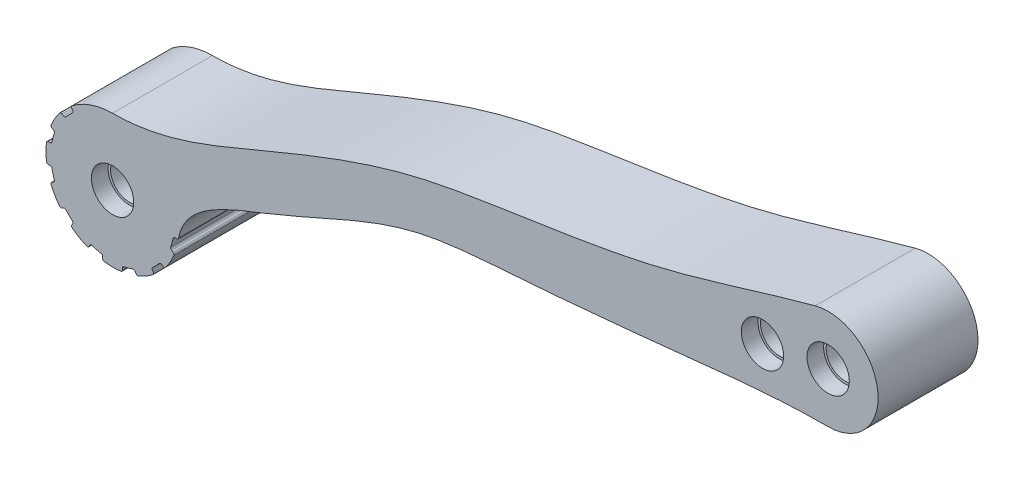
from build123d import *

# Parameters (mm, degrees)
CROQUIS2_R              = 6.35
SALIENTE_EXTRUIR1_DEPTH = 30
CROQUIS5_R              = 7.443338
CROQUIS5_R_2            = 2.5
CROQUIS5_R_3            = 7.334997
SALIENTE_EXTRUIR4_DEPTH = 30
CROQUIS6_R              = 6.35
CORTAR_EXTRUIR2_DEPTH   = 5
CROQUIS7_R              = 5.6
CORTAR_EXTRUIR3_DEPTH   = 30
CROQUIS8_R              = 6.35
CROQUIS8_R_2            = 5.6
CORTAR_EXTRUIR4_DEPTH   = 5
CROQUIS9_R              = 5.6
CORTAR_EXTRUIR6_DEPTH   = 30
CROQUIS10_R             = 6.35
CORTAR_EXTRUIR7_DEPTH   = 5
CROQUIS11_R             = 6.35
CORTAR_EXTRUIR8_DEPTH   = 5
CROQUIS14_R             = 6.35
CROQUIS14_R_2           = 5.6
SALIENTE_EXTRUIR5_DEPTH = 30
CROQUIS15_R             = 6.35
CORTAR_EXTRUIR9_DEPTH   = 5
CROQUIS16_R             = 6.35
CORTAR_EXTRUIR10_DEPTH  = 5
CORTAR_EXTRUIR11_DEPTH  = 30
CORTAR_EXTRUIR12_DEPTH  = 30


with BuildPart() as part:
    # Croquis2 → Saliente-Extruir1 (new body)
    with BuildSketch(Plane.XY):
        with BuildLine():
            ThreePointArc((180.032921, 90.655997), (194.905493, 107.607048), (176.163968, 120.14845))
            add(Edge.make_bspline(
                [(176.163968, 120.14845), (160.644333, 116.005277), (131.164286, 105.63785), (89.902158, 99.637145), (47.577901, 93.169368), (9.263632, 77.144895), (-20.334547, 64.717915), (-34.842858, 64.717915)],
                knots=[0, 0, 0, 0, 0.21855, 0.429652, 0.570361, 0.803751, 1, 1, 1, 1], degree=3))
            ThreePointArc((-34.842858, 64.717915), (-49.983575, 31.650448), (-15.057777, 41.793784))
            add(Edge.make_bspline(
                [(-15.057777, 41.793784), (-13.422876, 52.855749), (19.931915, 63.726677), (50.067366, 80.671919), (92.860268, 83.147923), (133.388153, 87.091721), (164.275892, 90.655997), (180.032921, 90.655997)],
                knots=[0, 0, 0, 0, 0.164668, 0.401388, 0.54424, 0.773428, 1, 1, 1, 1], degree=3))
        make_face()
        with Locations((160.312855, 102.321484)):
            Circle(CROQUIS2_R, mode=Mode.SUBTRACT)
        with Locations((180.032921, 105.655997)):
            Circle(CROQUIS2_R, mode=Mode.SUBTRACT)
        with Locations((-34.842858, 44.717915)):
            Circle(CROQUIS2_R, mode=Mode.SUBTRACT)
    extrude(amount=SALIENTE_EXTRUIR1_DEPTH)

    # Croquis5 → Saliente-Extruir4 (add)
    with BuildSketch(Plane(origin=(0, 0, 0), x_dir=(-1, 0, 0), z_dir=(0, 0, -1))):
        with Locations((-180.032921, 105.655997)):
            Circle(CROQUIS5_R)
        with Locations((-180.032921, 105.655997)):
            Circle(CROQUIS5_R_2, mode=Mode.SUBTRACT)
        with Locations((-160.312855, 102.321484)):
            Circle(CROQUIS5_R_3)
        with Locations((-160.312855, 102.321484)):
            Circle(CROQUIS5_R_2, mode=Mode.SUBTRACT)
    extrude(amount=-SALIENTE_EXTRUIR4_DEPTH)

    # Croquis6 → Cortar-Extruir2 (cut)
    with BuildSketch(Plane(origin=(0, 0, 0), x_dir=(-1, 0, 0), z_dir=(0, 0, -1))):
        with Locations((-160.312855, 102.321484)):
            Circle(CROQUIS6_R)
    extrude(amount=-CORTAR_EXTRUIR2_DEPTH, mode=Mode.SUBTRACT)

    # Croquis7 → Cortar-Extruir3 (cut)
    with BuildSketch(Plane(origin=(0, 0, 5), x_dir=(-1, 0, 0), z_dir=(0, 0, -1))):
        with Locations((-160.312855, 102.321484)):
            Circle(CROQUIS7_R)
    extrude(amount=-CORTAR_EXTRUIR3_DEPTH, mode=Mode.SUBTRACT)

    # Croquis8 → Cortar-Extruir4 (cut)
    with BuildSketch(Plane.XY.offset(30)):
        with Locations(Location((160.312855, 102.321484, 0), (0, 0, 180))):
            Circle(CROQUIS8_R)
        with Locations(Location((160.312855, 102.321484, 0), (0, 0, 180))):
            Circle(CROQUIS8_R_2, mode=Mode.SUBTRACT)
    extrude(amount=-CORTAR_EXTRUIR4_DEPTH, mode=Mode.SUBTRACT)

    # Croquis9 → Cortar-Extruir6 (cut)
    with BuildSketch(Plane(origin=(0, 0, 0), x_dir=(-1, 0, 0), z_dir=(0, 0, -1))):
        with Locations((-180.032921, 105.655997)):
            Circle(CROQUIS9_R)
    extrude(amount=-CORTAR_EXTRUIR6_DEPTH, mode=Mode.SUBTRACT)

    # Croquis10 → Cortar-Extruir7 (cut)
    with BuildSketch(Plane(origin=(0, 0, 0), x_dir=(-1, 0, 0), z_dir=(0, 0, -1))):
        with Locations((-180.032921, 105.655997)):
            Circle(CROQUIS10_R)
    extrude(amount=-CORTAR_EXTRUIR7_DEPTH, mode=Mode.SUBTRACT)

    # Croquis11 → Cortar-Extruir8 (cut)
    with BuildSketch(Plane.XY.offset(30)):
        with Locations(Location((180.032921, 105.655997, 0), (0, 0, 180))):
            Circle(CROQUIS11_R)
    extrude(amount=-CORTAR_EXTRUIR8_DEPTH, mode=Mode.SUBTRACT)

    # Croquis14 → Saliente-Extruir5 (add)
    with BuildSketch(Plane(origin=(0, 0, 0), x_dir=(-1, 0, 0), z_dir=(0, 0, -1))):
        with Locations((34.842858, 44.717915)):
            Circle(CROQUIS14_R)
        with Locations((34.842858, 44.717915)):
            Circle(CROQUIS14_R_2, mode=Mode.SUBTRACT)
    extrude(amount=-SALIENTE_EXTRUIR5_DEPTH)

    # Croquis15 → Cortar-Extruir9 (cut)
    with BuildSketch(Plane(origin=(0, 0, 0), x_dir=(-1, 0, 0), z_dir=(0, 0, -1))):
        with Locations((34.842858, 44.717915)):
            Circle(CROQUIS15_R)
    extrude(amount=-CORTAR_EXTRUIR9_DEPTH, mode=Mode.SUBTRACT)

    # Croquis16 → Cortar-Extruir10 (cut)
    with BuildSketch(Plane.XY.offset(30)):
        with Locations(Location((-34.842858, 44.717915, 0), (0, 0, 180))):
            Circle(CROQUIS16_R)
    extrude(amount=-CORTAR_EXTRUIR10_DEPTH, mode=Mode.SUBTRACT)

    # Croquis17 → Cortar-Extruir11 (cut)
    with BuildSketch(Plane(origin=(0, 0, 0), x_dir=(-1, 0, 0), z_dir=(0, 0, -1))):
        with BuildLine():
            Line((37.842858, 25.961909), (37.840378, 25.443819))
            ThreePointArc((37.840378, 25.443819), (37.696791, 25.063997), (37.337849, 24.87415))
            ThreePointArc((37.337849, 24.87415), (40.019239, 25.399398), (42.604016, 26.285215))
            ThreePointArc((42.604016, 26.285215), (42.198239, 26.270156), (41.883978, 26.527298))
            Line((41.883978, 26.527298), (41.622785, 26.974738))
            ThreePointArc((41.622785, 26.974738), (41.313642, 27.236121), (40.908833, 27.240674))
            ThreePointArc((40.908833, 27.240674), (39.631011, 26.848287), (38.328191, 26.549193))
            ThreePointArc((38.328191, 26.549193), (37.979893, 26.342846), (37.842858, 25.961909))
        make_face()
        with BuildLine():
            ThreePointArc((27.081701, 26.285215), (29.666477, 25.399398), (32.347868, 24.87415))
            ThreePointArc((32.347868, 24.87415), (31.988925, 25.063997), (31.845339, 25.443819))
            Line((31.845339, 25.443819), (31.842858, 25.961909))
            ThreePointArc((31.842858, 25.961909), (31.705824, 26.342846), (31.357526, 26.549193))
            ThreePointArc((31.357526, 26.549193), (30.054706, 26.848287), (28.776884, 27.240674))
            ThreePointArc((28.776884, 27.240674), (28.372075, 27.236121), (28.062932, 26.974738))
            Line((28.062932, 26.974738), (27.801738, 26.527298))
            ThreePointArc((27.801738, 26.527298), (27.487478, 26.270156), (27.081701, 26.285215))
        make_face()
        with BuildLine():
            ThreePointArc((47.075834, 29.524818), (47.141396, 29.124089), (46.925466, 28.780205))
            ThreePointArc((46.925466, 28.780205), (48.984994, 30.575779), (50.780568, 32.635307))
            ThreePointArc((50.780568, 32.635307), (50.436684, 32.419378), (50.035955, 32.484939))
            Line((50.035955, 32.484939), (49.586036, 32.741836))
            ThreePointArc((49.586036, 32.741836), (49.187618, 32.813629), (48.834767, 32.615168))
            ThreePointArc((48.834767, 32.615168), (47.924334, 31.636439), (46.945606, 30.726006))
            ThreePointArc((46.945606, 30.726006), (46.747144, 30.373155), (46.818937, 29.974738))
            Line((46.818937, 29.974738), (47.075834, 29.524818))
        make_face()
        with BuildLine():
            ThreePointArc((18.905149, 32.635307), (20.700723, 30.575779), (22.76025, 28.780205))
            ThreePointArc((22.76025, 28.780205), (22.544321, 29.124089), (22.609882, 29.524818))
            Line((22.609882, 29.524818), (22.866779, 29.974738))
            ThreePointArc((22.866779, 29.974738), (22.938572, 30.373155), (22.740111, 30.726006))
            ThreePointArc((22.740111, 30.726006), (21.761383, 31.636439), (20.85095, 32.615168))
            ThreePointArc((20.85095, 32.615168), (20.498099, 32.813629), (20.099681, 32.741836))
            Line((20.099681, 32.741836), (19.649761, 32.484939))
            ThreePointArc((19.649761, 32.484939), (19.249032, 32.419378), (18.905149, 32.635307))
        make_face()
        with BuildLine():
            ThreePointArc((53.033475, 37.676795), (53.290617, 37.362534), (53.275558, 36.956757))
            ThreePointArc((53.275558, 36.956757), (54.161375, 39.541534), (54.686624, 42.222924))
            ThreePointArc((54.686624, 42.222924), (54.496776, 41.863982), (54.116954, 41.720396))
            Line((54.116954, 41.720396), (53.598864, 41.717915))
            ThreePointArc((53.598864, 41.717915), (53.217928, 41.580881), (53.01158, 41.232583))
            ThreePointArc((53.01158, 41.232583), (52.712486, 39.929763), (52.320099, 38.65194))
            ThreePointArc((52.320099, 38.65194), (52.324652, 38.247132), (52.586036, 37.937988))
            Line((52.586036, 37.937988), (53.033475, 37.676795))
        make_face()
        with BuildLine():
            ThreePointArc((15.568762, 41.720396), (15.18894, 41.863982), (14.999093, 42.222924))
            Line((14.999093, 42.222924), (14.987998, 42.221529))
            add(Edge.make_bspline(
                [(15.057777, 41.793784), (15.03654, 41.937475), (15.01327, 42.080052), (14.987998, 42.221529)],
                knots=[0, 0, 0, 0, 0.002139, 0.002139, 0.002139, 0.002139], degree=3))
            ThreePointArc((15.057777, 41.793784), (15.581526, 39.33265), (16.410158, 36.956757))
            ThreePointArc((16.410158, 36.956757), (16.3951, 37.362534), (16.652242, 37.676795))
            Line((16.652242, 37.676795), (17.099681, 37.937988))
            ThreePointArc((17.099681, 37.937988), (17.361064, 38.247132), (17.365617, 38.65194))
            ThreePointArc((17.365617, 38.65194), (16.97323, 39.929763), (16.674136, 41.232583))
            ThreePointArc((16.674136, 41.232583), (16.467789, 41.580881), (16.086853, 41.717915))
            Line((16.086853, 41.717915), (15.568762, 41.720396))
        make_face()
        with BuildLine():
            ThreePointArc((54.116954, 47.715434), (54.496776, 47.571848), (54.686624, 47.212905))
            ThreePointArc((54.686624, 47.212905), (54.161375, 49.894296), (53.275558, 52.479072))
            ThreePointArc((53.275558, 52.479072), (53.290617, 52.073296), (53.033475, 51.759035))
            Line((53.033475, 51.759035), (52.586036, 51.497841))
            ThreePointArc((52.586036, 51.497841), (52.324652, 51.188698), (52.320099, 50.78389))
            ThreePointArc((52.320099, 50.78389), (52.712486, 49.506067), (53.01158, 48.203247))
            ThreePointArc((53.01158, 48.203247), (53.217928, 47.854949), (53.598864, 47.717915))
            Line((53.598864, 47.717915), (54.116954, 47.715434))
        make_face()
        with BuildLine():
            ThreePointArc((50.035955, 56.950891), (50.436684, 57.016452), (50.780568, 56.800523))
            ThreePointArc((50.780568, 56.800523), (48.984994, 58.860051), (46.925466, 60.655625))
            ThreePointArc((46.925466, 60.655625), (47.141396, 60.311741), (47.075834, 59.911012))
            Line((47.075834, 59.911012), (46.818937, 59.461092))
            ThreePointArc((46.818937, 59.461092), (46.747144, 59.062675), (46.945606, 58.709824))
            ThreePointArc((46.945606, 58.709824), (47.924334, 57.79939), (48.834767, 56.820662))
            ThreePointArc((48.834767, 56.820662), (49.187618, 56.622201), (49.586036, 56.693994))
            Line((49.586036, 56.693994), (50.035955, 56.950891))
        make_face()
    extrude(amount=-CORTAR_EXTRUIR11_DEPTH, mode=Mode.SUBTRACT)

    # Croquis19 → Cortar-Extruir12 (cut)
    with BuildSketch(Plane(origin=(0, 0, 0), x_dir=(-1, 0, 0), z_dir=(0, 0, -1))):
        with BuildLine():
            add(Edge.make_bspline(
                [(14.999093, 42.222924), (14.99115, 42.24649), (14.983101, 42.270016), (14.974951, 42.293506)],
                knots=[0, 0, 0, 0, 0.07094, 0.07094, 0.07094, 0.07094], degree=3))
            add(Edge.make_bspline(
                [(14.987998, 42.221529), (14.983706, 42.245553), (14.979357, 42.269545), (14.974951, 42.293506)],
                knots=[0.002139, 0.002139, 0.002139, 0.002139, 0.002502, 0.002502, 0.002502, 0.002502], degree=3))
            Line((14.987998, 42.221529), (14.999093, 42.222924))
        make_face()
        with BuildLine():
            ThreePointArc((15.568762, 41.720396), (15.195128, 41.870996), (14.999093, 42.222924))
            ThreePointArc((14.999093, 42.222924), (15.18894, 41.863982), (15.568762, 41.720396))
        make_face()
    extrude(amount=-CORTAR_EXTRUIR12_DEPTH, mode=Mode.SUBTRACT)


solid = part.part
